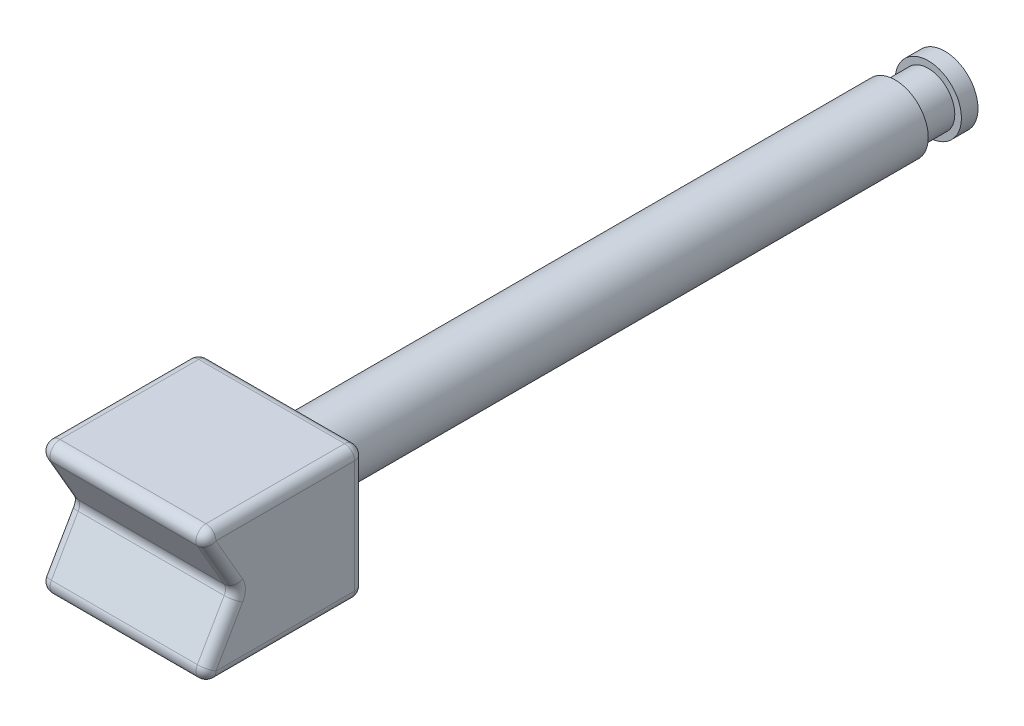
from build123d import *

# Parameters (mm, degrees)
ESQUISSE1_W             = 5
ESQUISSE1_H             = 5
BOSS_EXTRU_1_DEPTH      = 2
ENL_V_MAT_EXTRU_1_DEPTH = 6
ESQUISSE3_R             = 1
BOSS_EXTRU_2_DEPTH      = 20
ESQUISSE4_W             = 1
ESQUISSE4_H             = 0.2
CONG_3_R                = 0.3


with BuildPart() as part:
    # Esquisse1 → Boss.-Extru.1 (new body, symmetric)
    with BuildSketch(Plane(origin=(0, 0, 0), x_dir=(1, 0, 0), z_dir=(0, 1, 0))):
        Rectangle(ESQUISSE1_W, ESQUISSE1_H)
    extrude(amount=BOSS_EXTRU_1_DEPTH, both=True)

    # Esquisse2 → Enlèv. mat.-Extru.1 (cut, through all)
    with BuildSketch(Plane.ZY.offset(2.5)):
        Polygon((2.5, 2), (1.345299462, 0), (2.5, -2), align=None)
    extrude(amount=-ENL_V_MAT_EXTRU_1_DEPTH, mode=Mode.SUBTRACT)

    # Esquisse3 → Boss.-Extru.2 (add)
    with BuildSketch(Plane(origin=(0, 0, -2.5), x_dir=(-1, 0, 0), z_dir=(0, 0, -1))):
        Circle(ESQUISSE3_R)
    extrude(amount=BOSS_EXTRU_2_DEPTH)

    # Esquisse4 → Enlèvement de matière-Révolution1 (revolve, cut)
    with BuildSketch(Plane(origin=(0, 0, 0), x_dir=(0, 0, -1), z_dir=(1, 0, 0))):
        with Locations((21.5, 0.9)):
            Rectangle(ESQUISSE4_W, ESQUISSE4_H)
    revolve(axis=Axis((0, 0, -23.5), (0, 0, -1)), mode=Mode.SUBTRACT)

    # Congé3
    cong_3_edges = [part.edges().sort_by_distance(p)[0] for p in [
        (-2.5, 2, 0),
        (0, 2, 2.5),
        (2.5, -1, 1.922649731),
        (2.5, 1, 1.922649731),
        (0, 0, 1.345299462),
        (-2.5, 1, 1.922649731),
        (-2.5, -1, 1.922649731),
        (1, 0, -2.5),
        (2.5, 2, 0),
        (0, -2, 2.5),
        (-2.5, -2, 0),
        (0, -2, -2.5),
        (2.5, -2, 0),
        (-2.5, 0, -2.5),
        (2.5, 0, -2.5),
        (0, 2, -2.5),
    ]]
    fillet(cong_3_edges, radius=CONG_3_R)


solid = part.part
